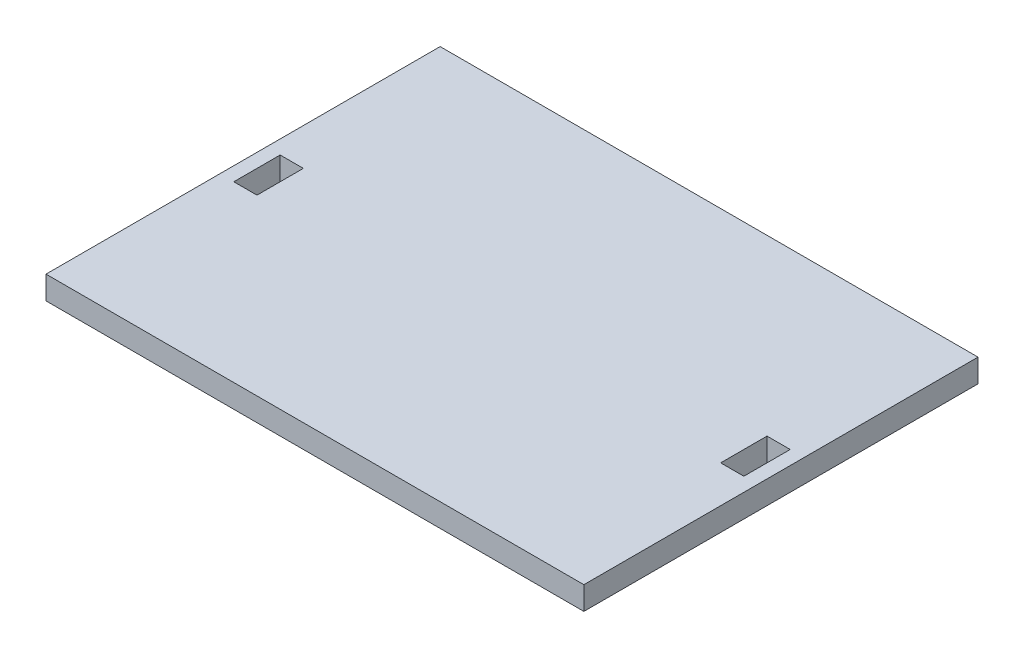
from build123d import *

# Parameters (mm, degrees)
SKETCH1_W           = 116
SKETCH1_H           = 85
BOSS_EXTRUDE1_DEPTH = 5
SKETCH3_W           = 5
SKETCH3_H           = 10
CUT_EXTRUDE1_DEPTH  = 10


with BuildPart() as part:
    # Sketch1 → Boss-Extrude1 (new body)
    with BuildSketch(Plane(origin=(0, 0, 0), x_dir=(1, 0, 0), z_dir=(0, 1, 0))):
        Rectangle(SKETCH1_W, SKETCH1_H)
    extrude(amount=BOSS_EXTRUDE1_DEPTH)

    # Sketch3 → Cut-Extrude1 (cut)
    with BuildSketch(Plane(origin=(0, 5, 0), x_dir=(1, 0, 0), z_dir=(0, 1, 0))):
        with Locations((-52.5, 0)):
            Rectangle(SKETCH3_W, SKETCH3_H)
        with Locations((52.5, 0)):
            Rectangle(SKETCH3_W, SKETCH3_H)
    extrude(amount=-CUT_EXTRUDE1_DEPTH, mode=Mode.SUBTRACT)


solid = part.part
